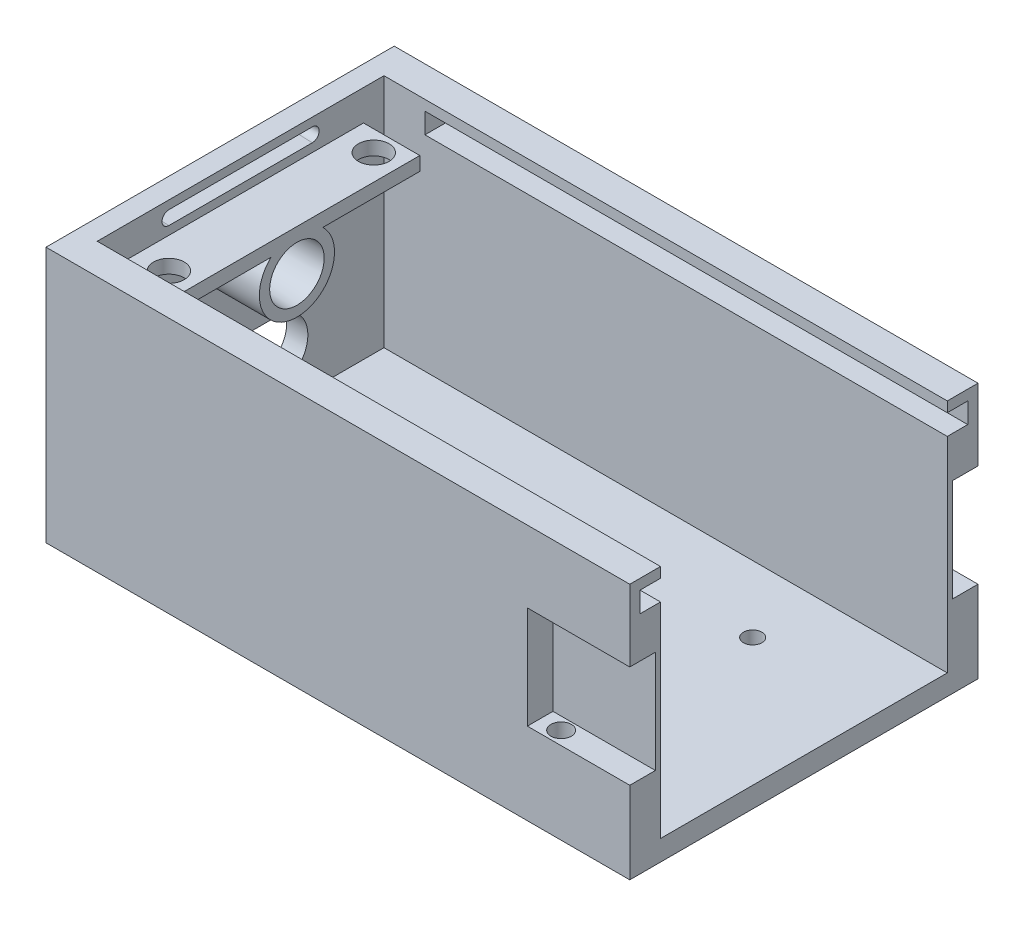
from build123d import *

# Parameters (mm, degrees)
SKETCH1_W                    = 59
SKETCH1_H                    = 34
SKETCH1_W_2                  = 55
SKETCH1_H_2                  = 28
BOSS_EXTRUDE1_DEPTH          = 25
SKETCH1_2_W                  = 55
SKETCH1_2_H                  = 28
BOSS_EXTRUDE2_DEPTH          = 2
SKETCH2_W                    = 2
SKETCH2_H                    = 34
CUT_EXTRUDE1_DEPTH           = 25
SKETCH3_R                    = 0.9
CUT_EXTRUDE2_DEPTH           = 25
CUT_EXTRUDE3_DEPTH           = 25
SKETCH5_W                    = 2
SKETCH5_H                    = 2
CUT_EXTRUDE4_DEPTH           = 51
SKETCH6_R                    = 3.668845882
BOSS_EXTRUDE3_DEPTH          = 5.5
SKETCH4_3_R                  = 2.4
CUT_EXTRUDE5_DEPTH           = 8
CUT_EXTRUDE5_DRAFT           = 2
CUT_EXTRUDE5_PROFILE_2_DEPTH = 8
CUT_EXTRUDE5_PROFILE_2_DRAFT = 2
CUT_EXTRUDE5_PROFILE_3_DEPTH = 8
CUT_EXTRUDE5_PROFILE_3_DRAFT = 2
SKETCH7_W                    = 24
SKETCH7_H                    = 1.341552338
BOSS_EXTRUDE4_DEPTH          = 5.5
SKETCH8_R                    = 1.5
CUT_EXTRUDE6_DEPTH           = 5.5
SKETCH9_W                    = 10
SKETCH9_H                    = 10
CUT_EXTRUDE7_DEPTH           = 2.5
SKETCH10_W                   = 10
SKETCH10_H                   = 10
CUT_EXTRUDE8_DEPTH           = 2.5
CUT_EXTRUDE9_DEPTH           = 12.5
CUT_EXTRUDE9_DEPTH_BACK      = 2.5
SKETCH11_R                   = 1
CUT_EXTRUDE10_DEPTH          = 12.5
CUT_EXTRUDE10_DEPTH_BACK     = 2.5
SKETCH12_R                   = 1


with BuildPart() as part:
    # Sketch1 → Boss-Extrude1 (new body)
    with BuildSketch(Plane(origin=(0, 0, 0), x_dir=(1, 0, 0), z_dir=(0, 1, 0))):
        with Locations((29.5, 17)):
            Rectangle(SKETCH1_W, SKETCH1_H)
        with Locations((29.5, 17)):
            Rectangle(SKETCH1_W_2, SKETCH1_H_2, mode=Mode.SUBTRACT)
    extrude(amount=BOSS_EXTRUDE1_DEPTH)

    # Sketch1_2 → Boss-Extrude2 (add)
    with BuildSketch(Plane(origin=(0, 0, 0), x_dir=(1, 0, 0), z_dir=(0, 1, 0))):
        with Locations((29.5, 17)):
            Rectangle(SKETCH1_2_W, SKETCH1_2_H)
    extrude(amount=BOSS_EXTRUDE2_DEPTH)

    # Sketch2 → Cut-Extrude1 (cut)
    with BuildSketch(Plane(origin=(0, 25, 0), x_dir=(1, 0, 0), z_dir=(0, 1, 0))):
        with Locations((58, 17)):
            Rectangle(SKETCH2_W, SKETCH2_H)
    extrude(amount=-CUT_EXTRUDE1_DEPTH, mode=Mode.SUBTRACT)

    # Sketch3 → Cut-Extrude2 (cut)
    with BuildSketch(Plane(origin=(0, 2, 0), x_dir=(1, 0, 0), z_dir=(0, 1, 0))):
        with Locations((4, 9.5)):
            Circle(SKETCH3_R)
        with Locations((4, 24.5)):
            Circle(SKETCH3_R)
        with Locations((44.5, 9.5)):
            Circle(SKETCH3_R)
        with Locations((44.5, 24.5)):
            Circle(SKETCH3_R)
    extrude(amount=-CUT_EXTRUDE2_DEPTH, mode=Mode.SUBTRACT)

    # Sketch4 → Cut-Extrude3 (cut)
    with BuildSketch(Plane.ZY):
        with BuildLine():
            Line((-13.5, 9.8), (-20.5, 9.8))
            ThreePointArc((-20.5, 9.8), (-23.5, 6.8), (-20.5, 3.8))
            Line((-20.5, 3.8), (-13.5, 3.8))
            ThreePointArc((-13.5, 3.8), (-10.5, 6.8), (-13.5, 9.8))
        make_face()
        with BuildLine():
            Line((-10, 24.1), (-24, 24.1))
            ThreePointArc((-24, 24.1), (-24.6, 23.5), (-24, 22.9))
            Line((-24, 22.9), (-10, 22.9))
            ThreePointArc((-10, 22.9), (-9.4, 23.5), (-10, 24.1))
        make_face()
    extrude(amount=-CUT_EXTRUDE3_DEPTH, mode=Mode.SUBTRACT)

    # Sketch5 → Cut-Extrude4 (cut)
    with BuildSketch(Plane(origin=(57, 0, 0), x_dir=(0, 0, -1), z_dir=(1, 0, 0))):
        with Locations((2, 23)):
            Rectangle(SKETCH5_W, SKETCH5_H)
        with Locations((32, 23)):
            Rectangle(SKETCH5_W, SKETCH5_H)
    extrude(amount=-CUT_EXTRUDE4_DEPTH, mode=Mode.SUBTRACT)

    # Sketch6 → Boss-Extrude3 (add)
    with BuildSketch(Plane(origin=(2, 0, 0), x_dir=(0, 0, -1), z_dir=(1, 0, 0))):
        with Locations((17, 18)):
            Circle(SKETCH6_R)
    extrude(amount=BOSS_EXTRUDE3_DEPTH)


with BuildPart() as cut_extrude5_tool:
    # Sketch4_3 → Cut-Extrude5 (with draft: the straight prism first)
    with BuildSketch(Plane.ZY):
        with Locations((-17, 18)):
            Circle(SKETCH4_3_R)
    extrude(amount=-CUT_EXTRUDE5_DEPTH)
    # Cut-Extrude5: the draft: its side faces are tilted about the plane it starts from
    cut_extrude5_sides = [cut_extrude5_tool.faces().sort_by_distance(p)[0] for p in [
        (4, 18, -19.4),
    ]]
    draft(cut_extrude5_sides, Plane.ZY, CUT_EXTRUDE5_DRAFT)


with BuildPart() as part_1:
    add(part.part)

    # Cut-Extrude5: cut by cut_extrude5_tool
    add(cut_extrude5_tool.part, mode=Mode.SUBTRACT)


with BuildPart() as cut_extrude5_profile_2_tool:
    # Sketch4_3 → Cut-Extrude5 profile 2 (with draft: the straight prism first)
    with BuildSketch(Plane.ZY):
        with BuildLine():
            ThreePointArc((-20.5, 9.8), (-23.5, 6.8), (-20.5, 3.8))
            Line((-20.5, 3.8), (-13.5, 3.8))
            ThreePointArc((-13.5, 3.8), (-10.5, 6.8), (-13.5, 9.8))
            Line((-13.5, 9.8), (-20.5, 9.8))
        make_face()
    extrude(amount=-CUT_EXTRUDE5_PROFILE_2_DEPTH)
    # Cut-Extrude5 profile 2: the draft: its side faces are tilted about the plane it starts from
    cut_extrude5_profile_2_sides = [cut_extrude5_profile_2_tool.faces().sort_by_distance(p)[0] for p in [
        (4, 3.8, -17),
        (4, 6.8, -10.5),
        (4, 9.8, -17),
        (4, 6.8, -23.5),
    ]]
    draft(cut_extrude5_profile_2_sides, Plane.ZY, CUT_EXTRUDE5_PROFILE_2_DRAFT)


with BuildPart() as part_2:
    add(part_1.part)

    # Cut-Extrude5 profile 2: cut by cut_extrude5_profile_2_tool
    add(cut_extrude5_profile_2_tool.part, mode=Mode.SUBTRACT)


with BuildPart() as cut_extrude5_profile_3_tool:
    # Sketch4_3 → Cut-Extrude5 profile 3 (with draft: the straight prism first)
    with BuildSketch(Plane.ZY):
        with BuildLine():
            ThreePointArc((-24, 24.1), (-24.6, 23.5), (-24, 22.9))
            Line((-24, 22.9), (-10, 22.9))
            ThreePointArc((-10, 22.9), (-9.4, 23.5), (-10, 24.1))
            Line((-10, 24.1), (-24, 24.1))
        make_face()
    extrude(amount=-CUT_EXTRUDE5_PROFILE_3_DEPTH)
    # Cut-Extrude5 profile 3: the draft: its side faces are tilted about the plane it starts from
    cut_extrude5_profile_3_sides = [cut_extrude5_profile_3_tool.faces().sort_by_distance(p)[0] for p in [
        (4, 23.5, -24.6),
        (4, 22.9, -17),
        (4, 23.5, -9.4),
        (4, 24.1, -17),
    ]]
    draft(cut_extrude5_profile_3_sides, Plane.ZY, CUT_EXTRUDE5_PROFILE_3_DRAFT)


with BuildPart() as part_3:
    add(part_2.part)

    # Cut-Extrude5 profile 3: cut by cut_extrude5_profile_3_tool
    add(cut_extrude5_profile_3_tool.part, mode=Mode.SUBTRACT)

    # Sketch7 → Boss-Extrude4 (add)
    with BuildSketch(Plane(origin=(2, 0, 0), x_dir=(0, 0, -1), z_dir=(1, 0, 0))):
        with Locations((17, 21.329223831)):
            Rectangle(SKETCH7_W, SKETCH7_H)
    extrude(amount=BOSS_EXTRUDE4_DEPTH)

    # Sketch8 → Cut-Extrude6 (cut)
    with BuildSketch(Plane(origin=(0, 22, 0), x_dir=(1, 0, 0), z_dir=(0, 1, 0))):
        with Locations((5, 7)):
            Circle(SKETCH8_R)
        with Locations((5, 27)):
            Circle(SKETCH8_R)
    extrude(amount=-CUT_EXTRUDE6_DEPTH, mode=Mode.SUBTRACT)

    # Sketch9 → Cut-Extrude7 (cut)
    with BuildSketch(Plane(origin=(0, 0, -34), x_dir=(-1, 0, 0), z_dir=(0, 0, -1))):
        with Locations((-52, 13)):
            Rectangle(SKETCH9_W, SKETCH9_H)
    extrude(amount=-CUT_EXTRUDE7_DEPTH, mode=Mode.SUBTRACT)

    # Sketch10 → Cut-Extrude8 (cut)
    with BuildSketch(Plane.XY):
        with Locations((52, 13)):
            Rectangle(SKETCH10_W, SKETCH10_H)
    extrude(amount=-CUT_EXTRUDE8_DEPTH, mode=Mode.SUBTRACT)

    # Sketch11 → Cut-Extrude9 (cut, two sides: drawn at the far end of the back side and taken through both)
    with BuildSketch(Plane(origin=(0, 18, 0), x_dir=(-1, 0, 0), z_dir=(0, -1, 0)).offset(-CUT_EXTRUDE9_DEPTH_BACK)):
        with Locations((-49, 1.3)):
            Circle(SKETCH11_R)
    extrude(amount=CUT_EXTRUDE9_DEPTH + CUT_EXTRUDE9_DEPTH_BACK, mode=Mode.SUBTRACT)

    # Sketch12 → Cut-Extrude10 (cut, two sides: drawn at the far end of the back side and taken through both)
    with BuildSketch(Plane(origin=(0, 18, 0), x_dir=(-1, 0, 0), z_dir=(0, -1, 0)).offset(-CUT_EXTRUDE10_DEPTH_BACK)):
        with Locations((-48.8, 32.7)):
            Circle(SKETCH12_R)
    extrude(amount=CUT_EXTRUDE10_DEPTH + CUT_EXTRUDE10_DEPTH_BACK, mode=Mode.SUBTRACT)


solid = part_3.part
